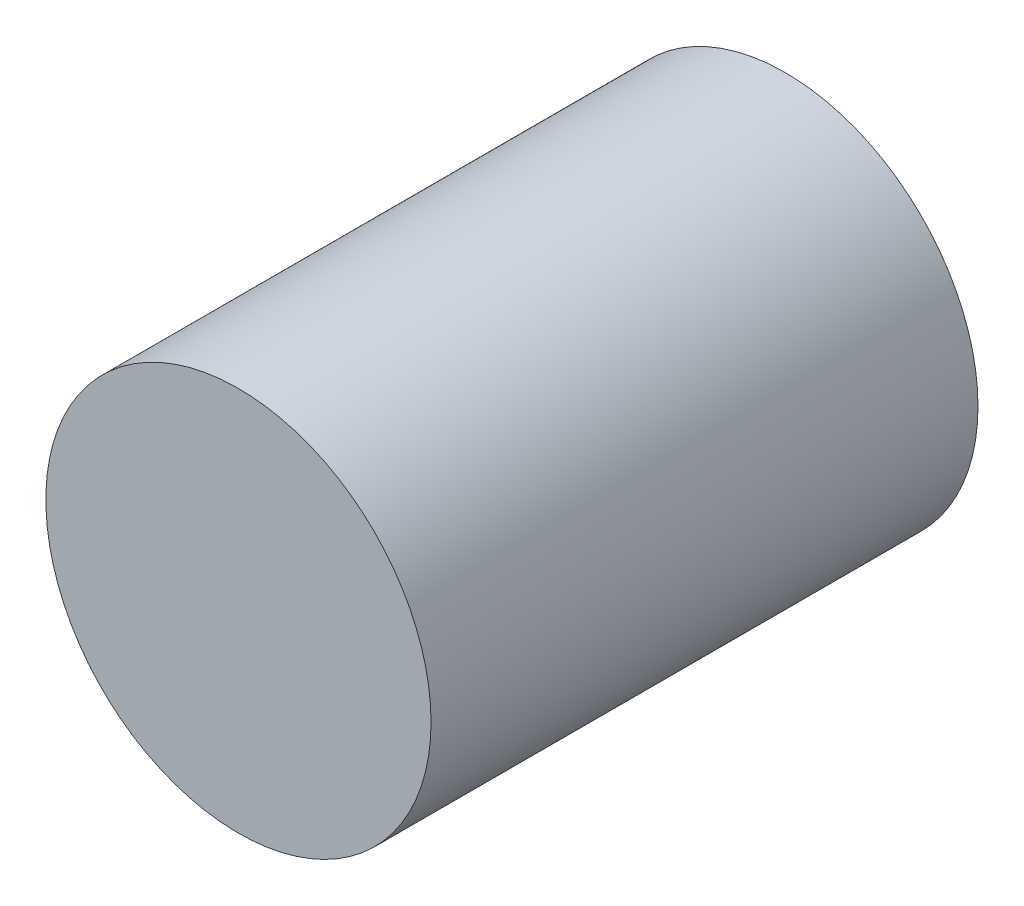
from build123d import *

# Parameters (mm, degrees)
SKETCH1_R           = 5
BOSS_EXTRUDE1_DEPTH = 14.2


with BuildPart() as part:
    # Sketch1 → Boss-Extrude1 (new body)
    with BuildSketch(Plane.XY):
        Circle(SKETCH1_R)
    extrude(amount=BOSS_EXTRUDE1_DEPTH)


solid = part.part
